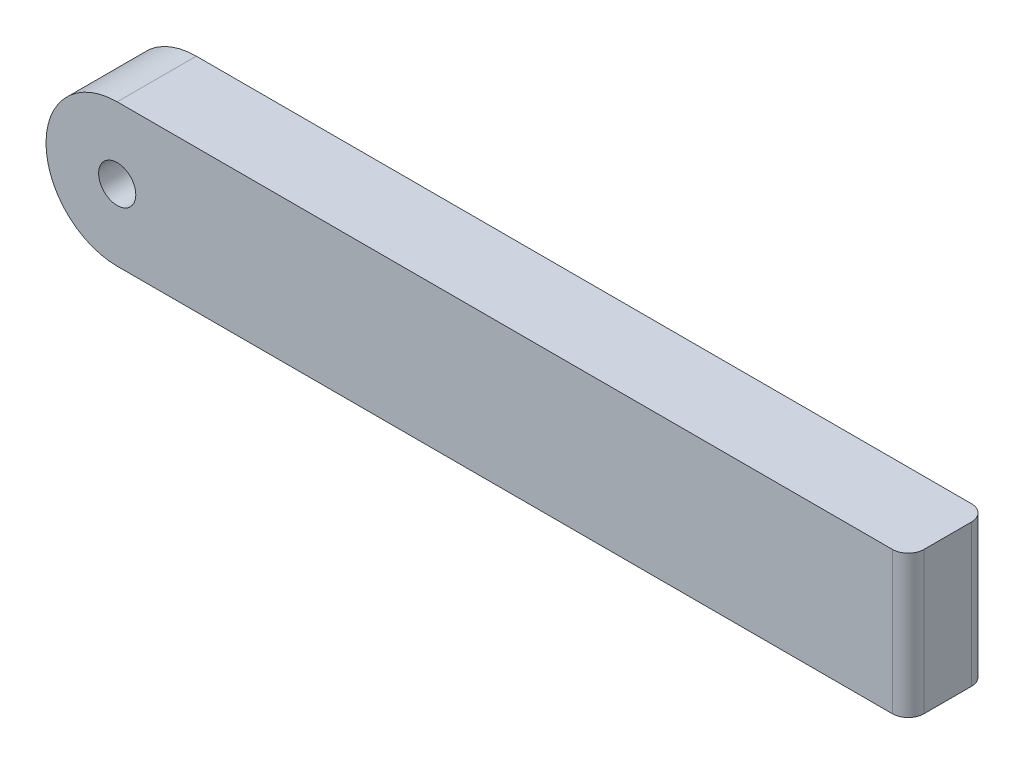
from build123d import *

# Parameters (mm, degrees)
ESQUISSE1_R        = 2.35
BOSS_EXTRU_1_DEPTH = 10
CONG_1_R           = 2


with BuildPart() as part:
    # Esquisse1 → Boss.-Extru.1 (new body)
    with BuildSketch(Plane.XY):
        with BuildLine():
            Line((0, 9), (100, 9))
            Line((100, 9), (100, -9))
            Line((100, -9), (0, -9))
            ThreePointArc((0, -9), (-9, 0), (0, 9))
        make_face()
        Circle(ESQUISSE1_R, mode=Mode.SUBTRACT)
    extrude(amount=BOSS_EXTRU_1_DEPTH)

    # Congé1
    cong_1_edges = [part.edges().sort_by_distance(p)[0] for p in [
        (100, 0, 10),
        (100, 0, 0),
    ]]
    fillet(cong_1_edges, radius=CONG_1_R)


solid = part.part
